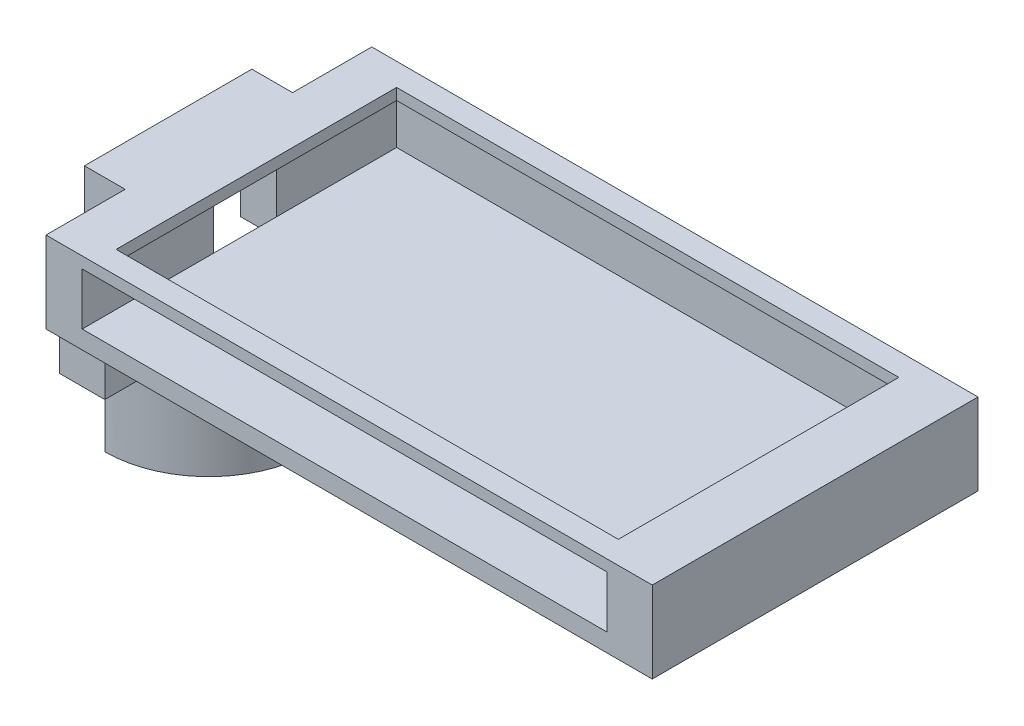
from build123d import *

# Parameters (mm, degrees)
SKETCH5_W                  = 116
SKETCH5_H                  = 67
MAIN_BODY_DEPTH            = 14
SKETCH6_W                  = 116
SKETCH6_H                  = 67
SKETCH6_W_2                = 111
SKETCH6_H_2                = 62
RAIL_DEPTH                 = 2.5
SKETCH8_W                  = 134
SKETCH8_H                  = 4
COVER_DEPTH                = 72
SKETCH9_W                  = 14
SKETCH9_H                  = 14
SIPM_WINDOW_DEPTH          = 8
TUBE_ADAPTER_DEPTH         = 30
RIGHT_SCREW_TERMINAL_DEPTH = 10
RIGHT_SCREW_HOLE_REACH     = 136
SKETCH12_R                 = 1.524
LEFT_SCREW_TERMINAL_DEPTH  = 10
LEFT_SCREW_HOLE_REACH      = 136
SKETCH14_R                 = 1.524
SKETCH15_W                 = 37
SKETCH15_H                 = 18
SIPM_MOUNT_DEPTH           = 9
SKETCH17_W                 = 8.8
SKETCH17_H                 = 36
CUT_EXTRUDE1_DEPTH         = 16
ADAPTER_HOLE_REACH         = 146
SKETCH18_R                 = 1.524
SKETCH19_W                 = 116
SKETCH19_H                 = 11.5
CUT_EXTRUDE2_DEPTH         = 10


with BuildPart() as part:
    # Sketch5 → Main Body (new body)
    with BuildSketch(Plane(origin=(0, 0, 0), x_dir=(1, 0, 0), z_dir=(0, 1, 0))):
        Polygon((-124, 0), (-134, 0), (-134, 72), (0, 72), (0, 0), (-1.95326153, 0), align=None)
        with Locations((-68, 36)):
            Rectangle(SKETCH5_W, SKETCH5_H, mode=Mode.SUBTRACT)
    extrude(amount=-MAIN_BODY_DEPTH)

    # Sketch6 → Rail (add)
    with BuildSketch(Plane(origin=(0, 0, 0), x_dir=(1, 0, 0), z_dir=(0, 1, 0))):
        with Locations((-68, 36)):
            Rectangle(SKETCH6_W, SKETCH6_H)
        with Locations((-68, 36)):
            Rectangle(SKETCH6_W_2, SKETCH6_H_2, mode=Mode.SUBTRACT)
    extrude(amount=-RAIL_DEPTH)

    # Sketch8 → Cover (add)
    with BuildSketch(Plane.XY):
        with Locations((-67, -16)):
            Rectangle(SKETCH8_W, SKETCH8_H)
    extrude(amount=-COVER_DEPTH)

    # Sketch9 → SiPM Window (cut)
    with BuildSketch(Plane.ZY.offset(134)):
        with Locations((-36, -11)):
            Rectangle(SKETCH9_W, SKETCH9_H)
    extrude(amount=-SIPM_WINDOW_DEPTH, mode=Mode.SUBTRACT)

    # Sketch10 → Tube Adapter (add)
    with BuildSketch(Plane.XZ.offset(18)):
        with BuildLine():
            Line((-134, -13), (-134, -16))
            ThreePointArc((-134, -16), (-114, -36), (-134, -56))
            Line((-134, -56), (-134, -59))
            ThreePointArc((-134, -59), (-111, -36), (-134, -13))
        make_face()
    extrude(amount=TUBE_ADAPTER_DEPTH)

    # Sketch11 → Right Screw Terminal (add)
    with BuildSketch(Plane.XZ.offset(18)):
        with BuildLine():
            Line((-134, -59), (-134, -69))
            Line((-134, -69), (-124, -69))
            Line((-124, -69), (-124, -56.712315177))
            ThreePointArc((-124, -56.712315177), (-128.870830919, -58.420785547), (-134, -59))
        make_face()
    extrude(amount=RIGHT_SCREW_TERMINAL_DEPTH)

    # Sketch12 → Right Screw Hole (cut, up to next)
    with BuildSketch(Plane.ZY.offset(134), mode=Mode.PRIVATE) as right_screw_hole_sk1:
        with Locations((-64, -23)):
            Circle(SKETCH12_R)
    right_screw_hole_tool1 = extrude(right_screw_hole_sk1.sketch, amount=-RIGHT_SCREW_HOLE_REACH, mode=Mode.PRIVATE) & part.part
    add(right_screw_hole_tool1.solids().sort_by_distance((-134, -23, -64))[0], mode=Mode.SUBTRACT)

    # Sketch13 → Left Screw Terminal (add)
    with BuildSketch(Plane(origin=(0, -18, 0), x_dir=(-1, 0, 0), z_dir=(0, -1, 0))):
        with BuildLine():
            Line((134, 13), (134, 3))
            Line((134, 3), (124, 3))
            Line((124, 3), (124, 15.287684823))
            ThreePointArc((124, 15.287684823), (128.870830919, 13.579214453), (134, 13))
        make_face()
    extrude(amount=LEFT_SCREW_TERMINAL_DEPTH)

    # Sketch14 → Left Screw Hole (cut, up to next)
    with BuildSketch(Plane.ZY.offset(134), mode=Mode.PRIVATE) as left_screw_hole_sk1:
        with Locations((-8, -23)):
            Circle(SKETCH14_R)
    left_screw_hole_tool1 = extrude(left_screw_hole_sk1.sketch, amount=-LEFT_SCREW_HOLE_REACH, mode=Mode.PRIVATE) & part.part
    add(left_screw_hole_tool1.solids().sort_by_distance((-134, -23, -8))[0], mode=Mode.SUBTRACT)

    # Sketch15 → SiPM Mount (add)
    with BuildSketch(Plane.ZY.offset(134)):
        with Locations((-36, -9)):
            Rectangle(SKETCH15_W, SKETCH15_H)
    extrude(amount=SIPM_MOUNT_DEPTH)

    # Sketch17 → Cut-Extrude1 (cut)
    with BuildSketch(Plane.XZ.offset(18)):
        with Locations((-138.4, -36)):
            Rectangle(SKETCH17_W, SKETCH17_H)
    extrude(amount=-CUT_EXTRUDE1_DEPTH, mode=Mode.SUBTRACT)

    # Sketch18 → Adapter Hole (cut, up to next)
    with BuildSketch(Plane.ZY.offset(144), mode=Mode.PRIVATE) as adapter_hole_sk1:
        with Locations((-36, -40.5)):
            Circle(SKETCH18_R)
    adapter_hole_tool1 = extrude(adapter_hole_sk1.sketch, amount=-ADAPTER_HOLE_REACH, mode=Mode.PRIVATE) & part.part
    add(adapter_hole_tool1.solids().sort_by_distance((-144, -40.5, -36))[0], mode=Mode.SUBTRACT)

    # Sketch19 → Cut-Extrude2 (cut)
    with BuildSketch(Plane(origin=(0, 0, -2.5), x_dir=(-1, 0, 0), z_dir=(0, 0, -1))):
        with Locations((68, -8.25)):
            Rectangle(SKETCH19_W, SKETCH19_H)
    extrude(amount=-CUT_EXTRUDE2_DEPTH, mode=Mode.SUBTRACT)


solid = part.part
